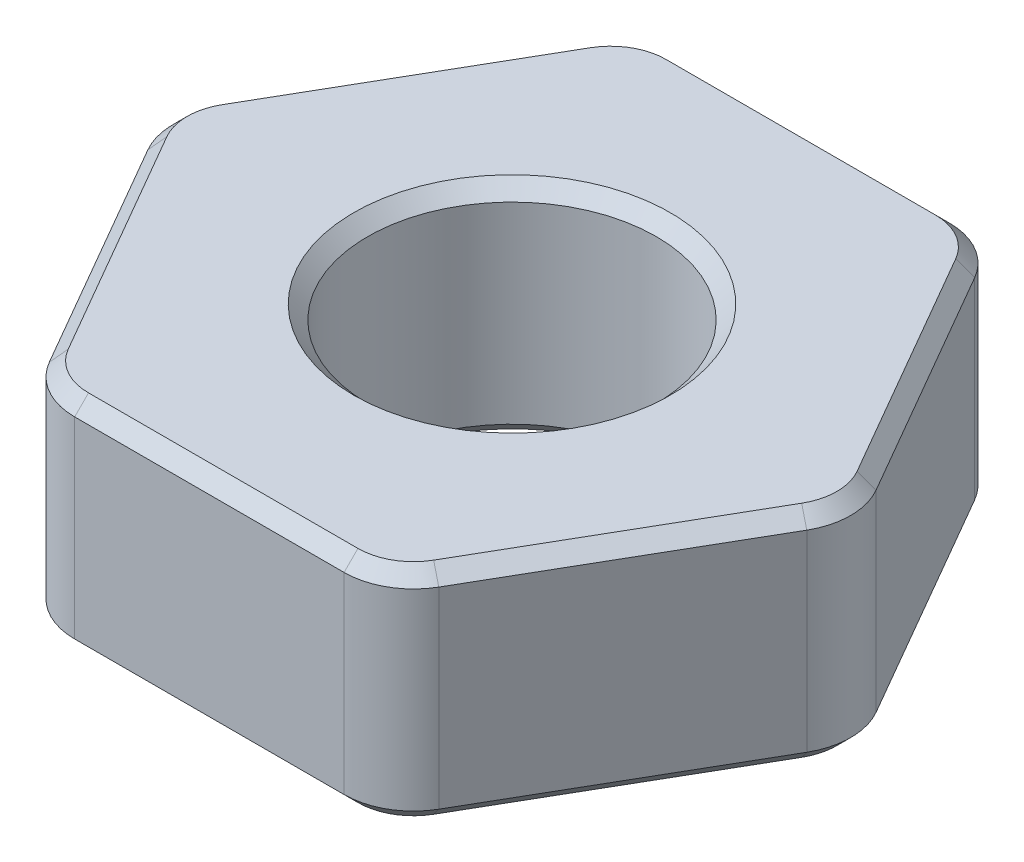
from build123d import *

# Parameters (mm, degrees)
SKETCH1_R           = 2.0828
BOSS_EXTRUDE1_DEPTH = 1.5875
FILLET1_R           = 1
CHAMFER1_SIZE       = 0.2


with BuildPart() as part:
    # Sketch1 → Boss-Extrude1 (new body, symmetric)
    with BuildSketch(Plane(origin=(0, 0, 0), x_dir=(1, 0, 0), z_dir=(0, 1, 0))):
        Polygon((2.520494769, 4.365625), (-2.520494769, 4.365625), (-5.040989538, 0), (-2.520494769, -4.365625), (2.520494769, -4.365625), (5.040989538, 0), align=None)
        Circle(SKETCH1_R, mode=Mode.SUBTRACT)
    extrude(amount=BOSS_EXTRUDE1_DEPTH, both=True)

    # Fillet1
    fillet1_edges = [part.edges().sort_by_distance(p)[0] for p in [
        (5.040989538, 0, 0),
        (2.520494769, 0, 4.365625),
        (-2.520494769, 0, 4.365625),
        (-5.040989538, 0, 0),
        (-2.520494769, 0, -4.365625),
        (2.520494769, 0, -4.365625),
    ]]
    fillet(fillet1_edges, radius=FILLET1_R)

    # Chamfer1
    chamfer1_edges = [part.edges().sort_by_distance(p)[0] for p in [
        (-2.0828, -1.5875, 0),
        (-2.0828, 1.5875, 0),
        (3.780742153, -1.5875, -2.1828125),
        (3.780742153, 1.5875, -2.1828125),
        (3.780742153, -1.5875, 2.1828125),
        (0, -1.5875, 4.365625),
        (-3.780742153, -1.5875, 2.1828125),
        (-3.780742153, -1.5875, -2.1828125),
        (0, -1.5875, -4.365625),
        (-2.4431445, -1.5875, 4.231650404),
        (2.4431445, -1.5875, -4.231650404),
        (-2.4431445, -1.5875, -4.231650404),
        (-4.886288999, -1.5875, 0),
        (2.4431445, -1.5875, 4.231650404),
        (4.886288999, -1.5875, 0),
        (3.780742153, 1.5875, 2.1828125),
        (0, 1.5875, -4.365625),
        (-3.780742153, 1.5875, -2.1828125),
        (-3.780742153, 1.5875, 2.1828125),
        (0, 1.5875, 4.365625),
        (-2.4431445, 1.5875, 4.231650404),
        (2.4431445, 1.5875, -4.231650404),
        (-2.4431445, 1.5875, -4.231650404),
        (-4.886288999, 1.5875, 0),
        (2.4431445, 1.5875, 4.231650404),
        (4.886288999, 1.5875, 0),
    ]]
    chamfer(chamfer1_edges, length=CHAMFER1_SIZE)


solid = part.part
